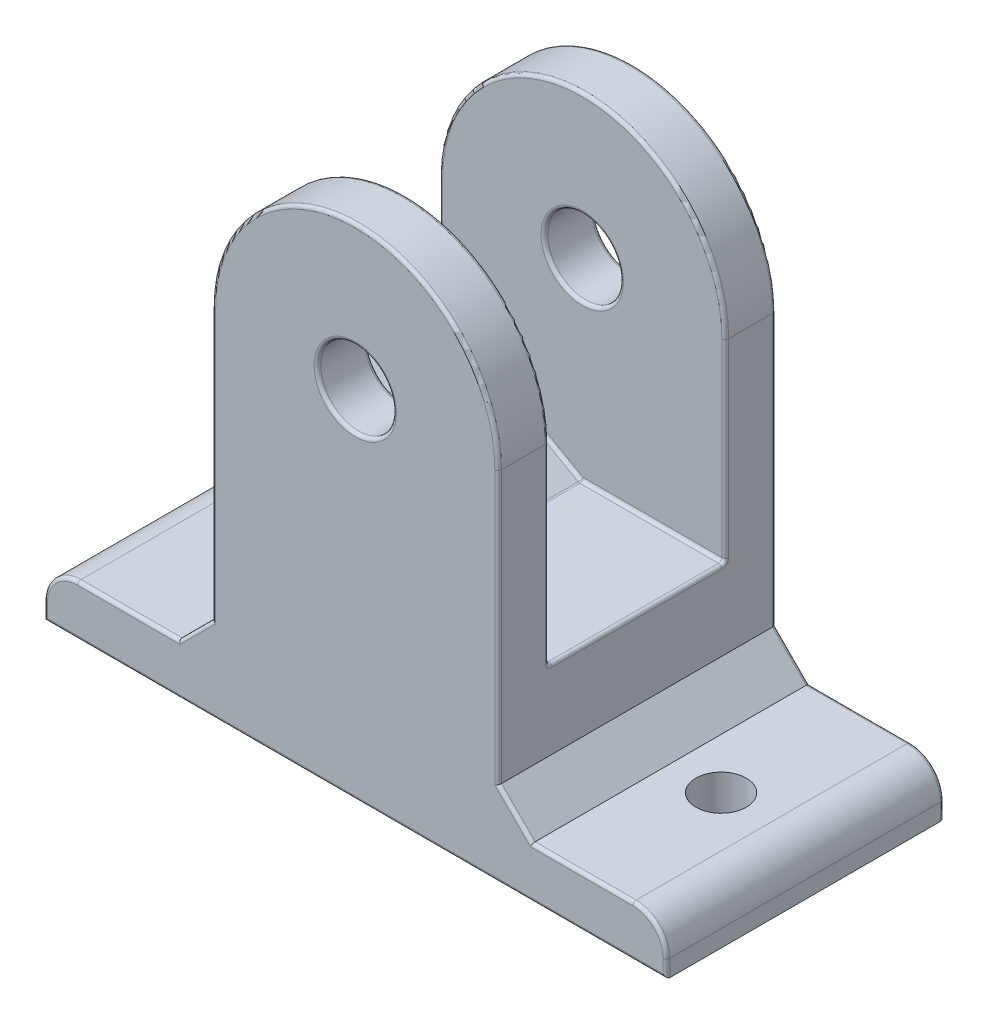
from build123d import *

# Parameters (mm, degrees)
SKETCH1_R           = 2.25
BOSS_EXTRUDE1_DEPTH = 3
BOSS_EXTRUDE2_DEPTH = 10.5
SKETCH3_R           = 2.25
BOSS_EXTRUDE3_DEPTH = 3
SKETCH4_W           = 10
SKETCH4_H           = 16.5
SKETCH4_R           = 1.5
BOSS_EXTRUDE4_DEPTH = 3
CHAMFER1_SIZE       = 2
FILLET1_R           = 2
FILLET2_R           = 0.2


with BuildPart() as part:
    # Sketch1 → Boss-Extrude1 (new body)
    with BuildSketch(Plane.XY):
        with BuildLine():
            Line((8.5, 21.15), (8.5, 0))
            Line((8.5, 0), (-8.5, 0))
            Line((-8.5, 0), (-8.5, 21.15))
            ThreePointArc((-8.5, 21.15), (0, 29.65), (8.5, 21.15))
        make_face()
        with Locations((0, 21.15)):
            Circle(SKETCH1_R, mode=Mode.SUBTRACT)
    extrude(amount=BOSS_EXTRUDE1_DEPTH)

    # Sketch2 → Boss-Extrude2 (add)
    with BuildSketch(Plane(origin=(0, 0, 0), x_dir=(-1, 0, 0), z_dir=(0, 0, -1))):
        Polygon((-8.5, 9.684851267), (0, 9.684851267), (8.5, 14.51624495), (8.5, 0), (-8.5, 0), align=None)
    extrude(amount=BOSS_EXTRUDE2_DEPTH)

    # Sketch3 → Boss-Extrude3 (add)
    with BuildSketch(Plane(origin=(0, 0, -10.5), x_dir=(-1, 0, 0), z_dir=(0, 0, -1))):
        with BuildLine():
            Line((-8.5, 21.15), (-8.5, 0))
            Line((-8.5, 0), (8.5, 0))
            Line((8.5, 0), (8.5, 21.15))
            ThreePointArc((8.5, 21.15), (0, 29.65), (-8.5, 21.15))
        make_face()
        with Locations((0, 21.15)):
            Circle(SKETCH3_R, mode=Mode.SUBTRACT)
    extrude(amount=BOSS_EXTRUDE3_DEPTH)

    # Sketch4 → Boss-Extrude4 (add)
    with BuildSketch(Plane(origin=(0, 0, 0), x_dir=(1, 0, 0), z_dir=(0, 1, 0))):
        with Locations((13.5, 5.25)):
            Rectangle(SKETCH4_W, SKETCH4_H)
        with Locations((13.5, 5.25)):
            Circle(SKETCH4_R, mode=Mode.SUBTRACT)
        with Locations((-13.5, 5.25)):
            Rectangle(SKETCH4_W, SKETCH4_H)
        with Locations((-13.5, 5.25)):
            Circle(SKETCH4_R, mode=Mode.SUBTRACT)
    extrude(amount=BOSS_EXTRUDE4_DEPTH)

    # Chamfer1
    chamfer1_edges = [part.edges().sort_by_distance(p)[0] for p in [
        (8.5, 3, -5.25),
        (-8.5, 3, -5.25),
    ]]
    chamfer(chamfer1_edges, length=CHAMFER1_SIZE)

    # Fillet1
    fillet1_edges = [part.edges().sort_by_distance(p)[0] for p in [
        (18.5, 3, -5.25),
        (-18.5, 3, -5.25),
    ]]
    fillet(fillet1_edges, radius=FILLET1_R)

    # Fillet2
    fillet2_edges = [part.edges().sort_by_distance(p)[0] for p in [
        (0, 29.65, 3),
        (-2.25, 21.15, 0),
        (-2.25, 21.15, 3),
        (-8.5, 13.075, 3),
        (8.5, 15.417425634, 0),
        (8.5, 9.684851267, -5.25),
        (-4.25, 12.100548109, 0),
        (-8.5, 14.51624495, -5.25),
        (4.25, 9.684851267, 0),
        (0, 9.684851267, -5.25),
        (-4.25, 12.100548109, -10.5),
        (4.25, 9.684851267, -10.5),
        (0, 29.65, -13.5),
        (8.5, 13.075, -13.5),
        (0, 0, -13.5),
        (2.25, 21.15, -10.5),
        (0, 29.65, -10.5),
        (8.5, 15.417425634, -10.5),
        (-8.5, 17.833122475, -10.5),
        (2.25, 21.15, -13.5),
        (0, 0, 3),
        (-8.5, 17.833122475, 0),
        (0, 29.65, 0),
        (-13.5, 3, -13.5),
        (-8.5, 13.075, -13.5),
        (13.5, 3, 3),
        (8.5, 13.075, 3),
        (-9.5, 4, -13.5),
        (-9.5, 4, 3),
        (9.5, 4, 3),
        (9.5, 4, -13.5),
        (-13.5, 3, 3),
        (18.5, 0.5, 3),
        (-18.5, 0.5, 3),
        (17.914213562, 2.414213562, 3),
        (-17.914213562, 2.414213562, 3),
        (-18.5, 0.5, -13.5),
        (13.5, 3, -13.5),
        (18.5, 0.5, -13.5),
        (17.914213562, 2.414213562, -13.5),
        (-17.914213562, 2.414213562, -13.5),
    ]]
    fillet(fillet2_edges, radius=FILLET2_R)


solid = part.part
